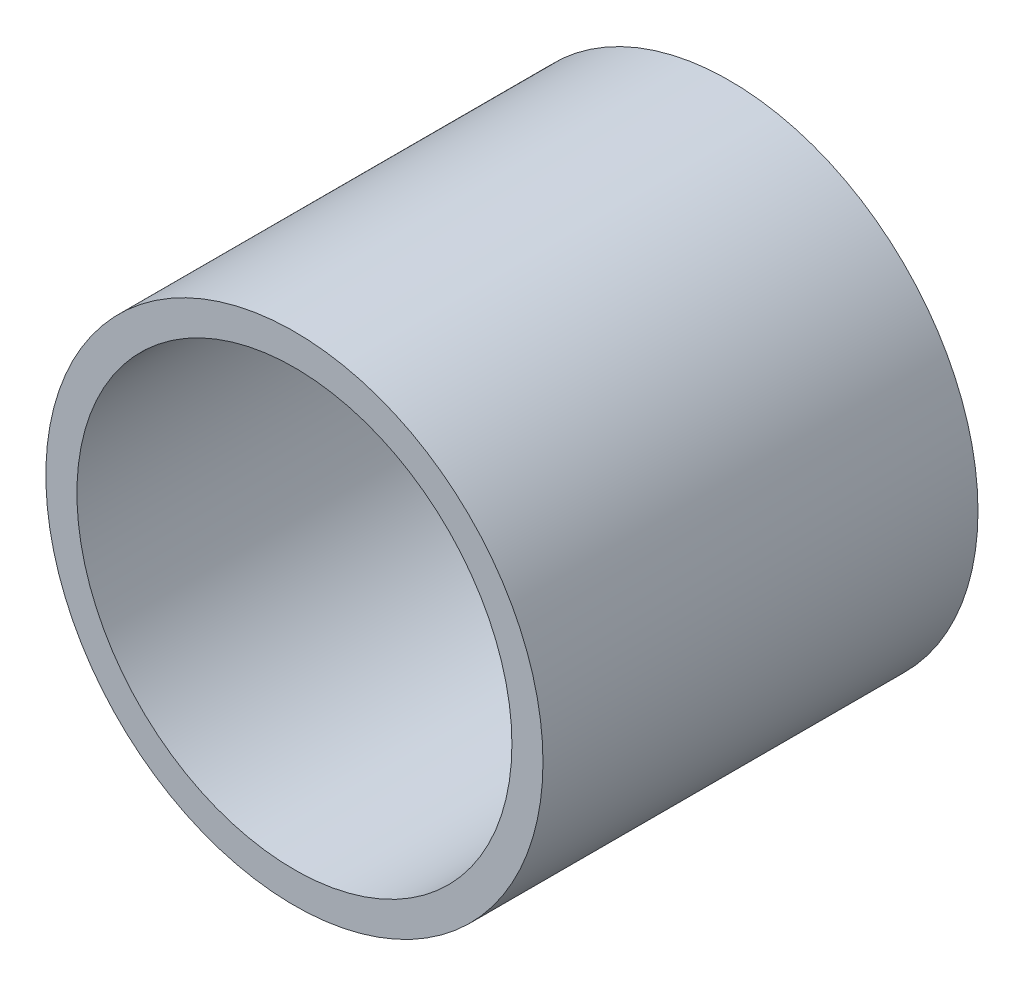
from build123d import *

# Parameters (mm, degrees)
SKETCH1_R           = 6.35
SKETCH1_R_2         = 5.55625
BOSS_EXTRUDE1_DEPTH = 11.1125


with BuildPart() as part:
    # Sketch1 → Boss-Extrude1 (new body)
    with BuildSketch(Plane.XY):
        Circle(SKETCH1_R)
        Circle(SKETCH1_R_2, mode=Mode.SUBTRACT)
    extrude(amount=BOSS_EXTRUDE1_DEPTH)


solid = part.part
